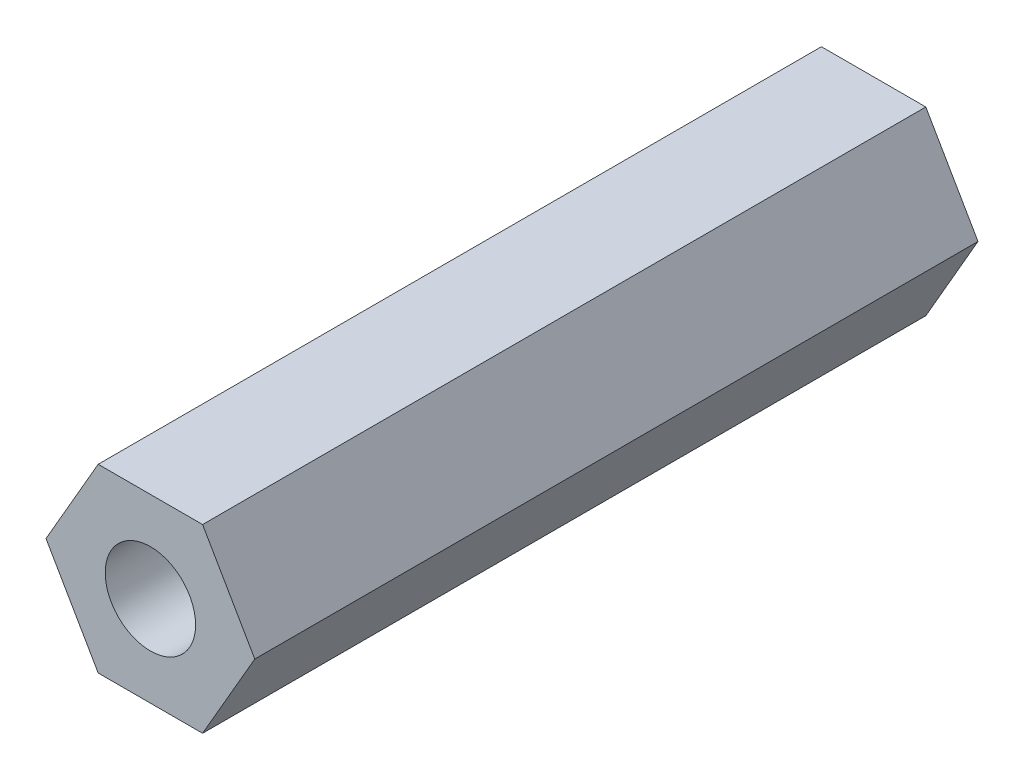
from build123d import *

# Parameters (mm, degrees)
EXTRUDE_1_DEPTH = 20
M3X0_5_1_D      = 2.5


with BuildPart() as part:
    # 草圖1 → 填料-伸長1 (new body)
    with BuildSketch(Plane.XY):
        Polygon((-1.443375673, 2.5), (-2.886751346, 0), (-1.443375673, -2.5), (1.443375673, -2.5), (2.886751346, 0), (1.443375673, 2.5), align=None)
    extrude(amount=EXTRUDE_1_DEPTH)

    # M3x0.5 螺紋孔1 (through all)
    with Locations(Plane.XY.offset(20)):
        with Locations((0, 0)):
            Hole(M3X0_5_1_D / 2)


solid = part.part
